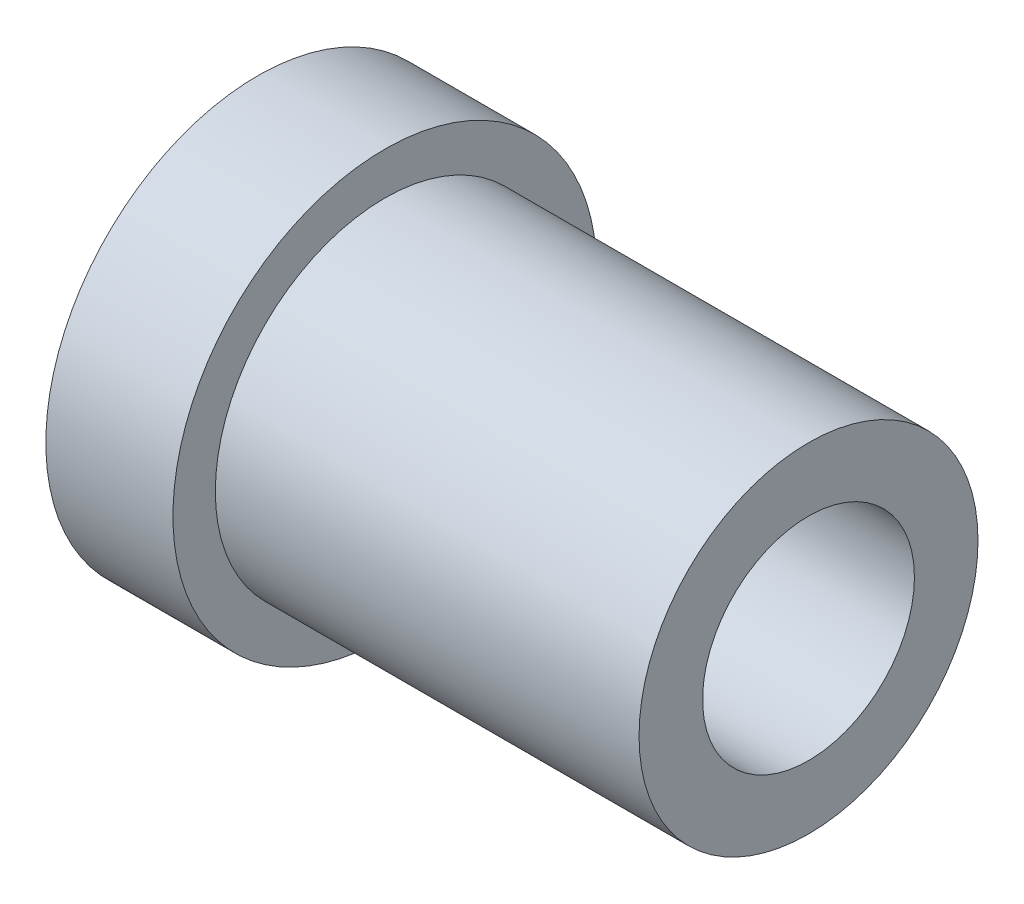
from build123d import *

# Parameters (mm, degrees)
ESQUISSE1_R             = 4
EXTRUSION1_DEPTH        = 10
EXTRUSION1_DEPTH_BACK   = 3
ESQUISSE2_R             = 5
EXTRUSION2_DEPTH        = 3
ENL_V_MAT_EXTRU_1_DEPTH = 3
ESQUISSE4_R             = 2.5
ENL_V_MAT_EXTRU_2_DEPTH = 14


with BuildPart() as part:
    # Esquisse1 → Extrusion1 (new body, two sides)
    with BuildSketch(Plane(origin=(0, 0, 0), x_dir=(0, 0, -1), z_dir=(1, 0, 0))) as extrusion1_sk:
        Circle(ESQUISSE1_R)
    extrude(amount=EXTRUSION1_DEPTH)
    extrude(extrusion1_sk.sketch, amount=-EXTRUSION1_DEPTH_BACK)

    # Esquisse2 → Extrusion2 (add)
    with BuildSketch(Plane(origin=(0, 0, 0), x_dir=(0, 0, -1), z_dir=(1, 0, 0))):
        Circle(ESQUISSE2_R)
    extrude(amount=-EXTRUSION2_DEPTH)

    # Esquisse3 → Enlèv. mat.-Extru.1 (cut)
    with BuildSketch(Plane.ZY.offset(3)):
        Polygon((0, 2.886751346), (-2.5, 1.443375673), (-2.5, -1.443375673), (0, -2.886751346), (2.5, -1.443375673), (2.5, 1.443375673), align=None)
    extrude(amount=-ENL_V_MAT_EXTRU_1_DEPTH, mode=Mode.SUBTRACT)

    # Esquisse4 → Enlèv. mat.-Extru.2 (cut, through all)
    with BuildSketch(Plane(origin=(10, 0, 0), x_dir=(0, 0, -1), z_dir=(1, 0, 0))):
        Circle(ESQUISSE4_R)
    extrude(amount=-ENL_V_MAT_EXTRU_2_DEPTH, mode=Mode.SUBTRACT)


solid = part.part
